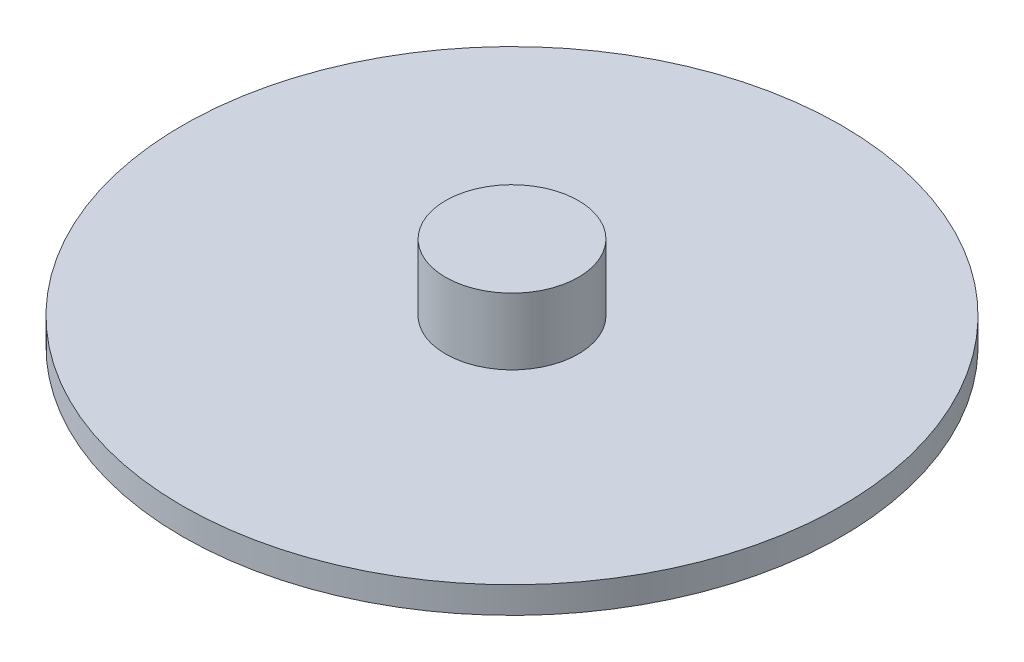
from build123d import *

# Parameters (mm, degrees)
SKETCH1_R           = 31.496
BOSS_EXTRUDE1_DEPTH = 2.54
SKETCH2_R           = 6.35
BOSS_EXTRUDE2_DEPTH = 6.35


with BuildPart() as part:
    # Sketch1 → Boss-Extrude1 (new body)
    with BuildSketch(Plane(origin=(0, 0, 0), x_dir=(1, 0, 0), z_dir=(0, 1, 0))):
        Circle(SKETCH1_R)
    extrude(amount=BOSS_EXTRUDE1_DEPTH)

    # Sketch2 → Boss-Extrude2 (add)
    with BuildSketch(Plane(origin=(0, 2.54, 0), x_dir=(1, 0, 0), z_dir=(0, 1, 0))):
        Circle(SKETCH2_R)
    extrude(amount=BOSS_EXTRUDE2_DEPTH)


solid = part.part
